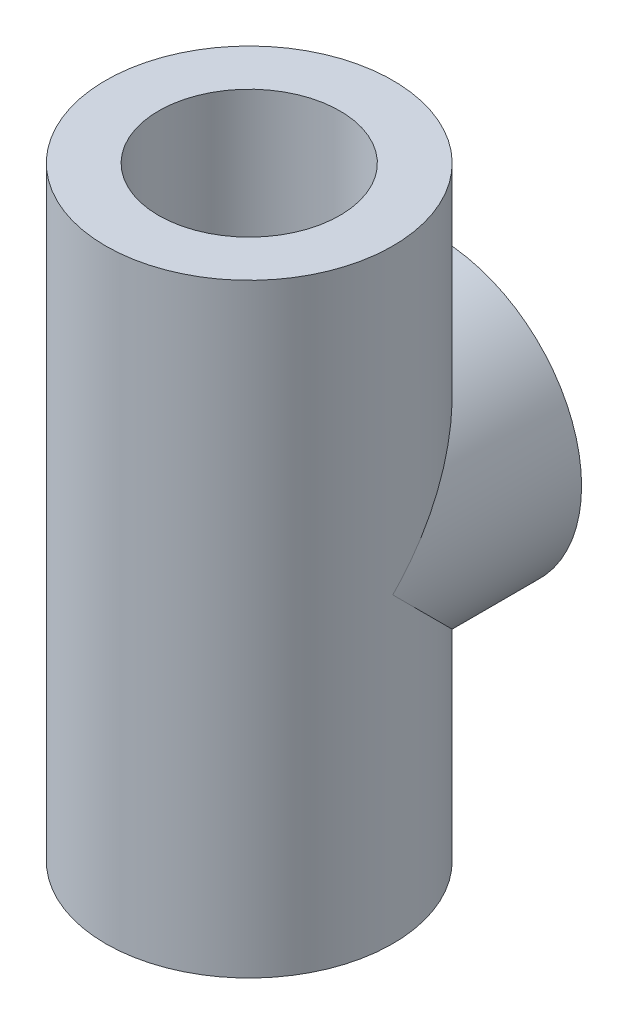
from build123d import *

# Parameters (mm, degrees)
SKETCH1_R               = 47.5
SKETCH1_R_2             = 30
BOSS_EXTRUDE1_DEPTH     = 200
BOSS_EXTRUDE2_REACH     = 112
SKETCH2_R               = 27
SKETCH2_R_2             = 47.5
SKETCH3_R               = 27
CUT_EXTRUDE1_DEPTH      = 1
CUT_EXTRUDE1_DEPTH_BACK = 4
SKETCH4_R               = 5
CUT_EXTRUDE2_DEPTH      = 20


with BuildPart() as part:
    # Sketch1 → Boss-Extrude1 (new body)
    with BuildSketch(Plane(origin=(0, 0, 0), x_dir=(1, 0, 0), z_dir=(0, 1, 0))):
        Circle(SKETCH1_R)
        Circle(SKETCH1_R_2, mode=Mode.SUBTRACT)
    extrude(amount=BOSS_EXTRUDE1_DEPTH)

    # Sketch2 → Boss-Extrude2 (add, up to next)
    with BuildSketch(Plane.XY.offset(-62.5), mode=Mode.PRIVATE) as boss_extrude2_sk1:
        with Locations((0, 100)):
            Circle(SKETCH2_R)
    boss_extrude2_tool1 = extrude(boss_extrude2_sk1.sketch, amount=BOSS_EXTRUDE2_REACH, mode=Mode.PRIVATE) - part.part
    add(boss_extrude2_tool1.solids().sort_by_distance((0, 100, -62.5))[0])
    # Sketch2 → Boss-Extrude2 (add, up to next)
    with BuildSketch(Plane.XY.offset(-62.5), mode=Mode.PRIVATE) as boss_extrude2_sk2:
        with Locations((0, 100)):
            Circle(SKETCH2_R_2)
        with Locations((0, 100)):
            Circle(SKETCH2_R, mode=Mode.SUBTRACT)
    boss_extrude2_tool2 = extrude(boss_extrude2_sk2.sketch, amount=BOSS_EXTRUDE2_REACH, mode=Mode.PRIVATE) - part.part
    add(boss_extrude2_tool2.solids().sort_by_distance((-46.156497, 100, -62.5))[0])

    # Sketch3 → Cut-Extrude1 (cut, two sides)
    with BuildSketch(Plane(origin=(0, 0, -62.5), x_dir=(-1, 0, 0), z_dir=(0, 0, -1))) as cut_extrude1_sk:
        with Locations((0, 100)):
            Circle(SKETCH3_R)
    extrude(amount=CUT_EXTRUDE1_DEPTH, mode=Mode.SUBTRACT)
    extrude(cut_extrude1_sk.sketch, amount=-CUT_EXTRUDE1_DEPTH_BACK, mode=Mode.SUBTRACT)

    # Sketch4 → Cut-Extrude2 (cut)
    with BuildSketch(Plane(origin=(0, 0, -62.5), x_dir=(-1, 0, 0), z_dir=(0, 0, -1))):
        with Locations((0, 138)):
            Circle(SKETCH4_R)
        with Locations((38, 100)):
            Circle(SKETCH4_R)
        with Locations((0, 62)):
            Circle(SKETCH4_R)
        with Locations((-38, 100)):
            Circle(SKETCH4_R)
    extrude(amount=-CUT_EXTRUDE2_DEPTH, mode=Mode.SUBTRACT)


solid = part.part
